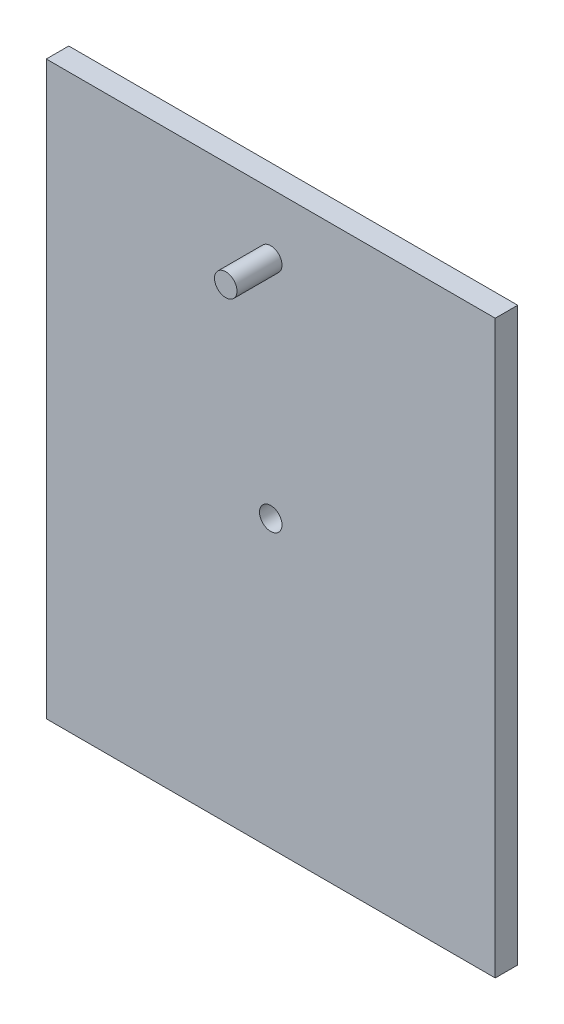
from build123d import *

# Parameters (mm, degrees)
SKETCH1_W           = 399.143716184
SKETCH1_H           = 508
SKETCH1_R           = 10
BOSS_EXTRUDE1_DEPTH = 20
SKETCH1_2_R         = 10
BOSS_EXTRUDE2_DEPTH = 60


with BuildPart() as part:
    # Sketch1 → Boss-Extrude1 (new body)
    with BuildSketch(Plane.XY):
        Rectangle(SKETCH1_W, SKETCH1_H)
        Circle(SKETCH1_R, mode=Mode.SUBTRACT)
        with Locations((0, 200)):
            Circle(SKETCH1_R, mode=Mode.SUBTRACT)
    extrude(amount=BOSS_EXTRUDE1_DEPTH)

    # Sketch1_2 → Boss-Extrude2 (add)
    with BuildSketch(Plane.XY):
        with Locations((0, 200)):
            Circle(SKETCH1_2_R)
    extrude(amount=BOSS_EXTRUDE2_DEPTH)


solid = part.part
